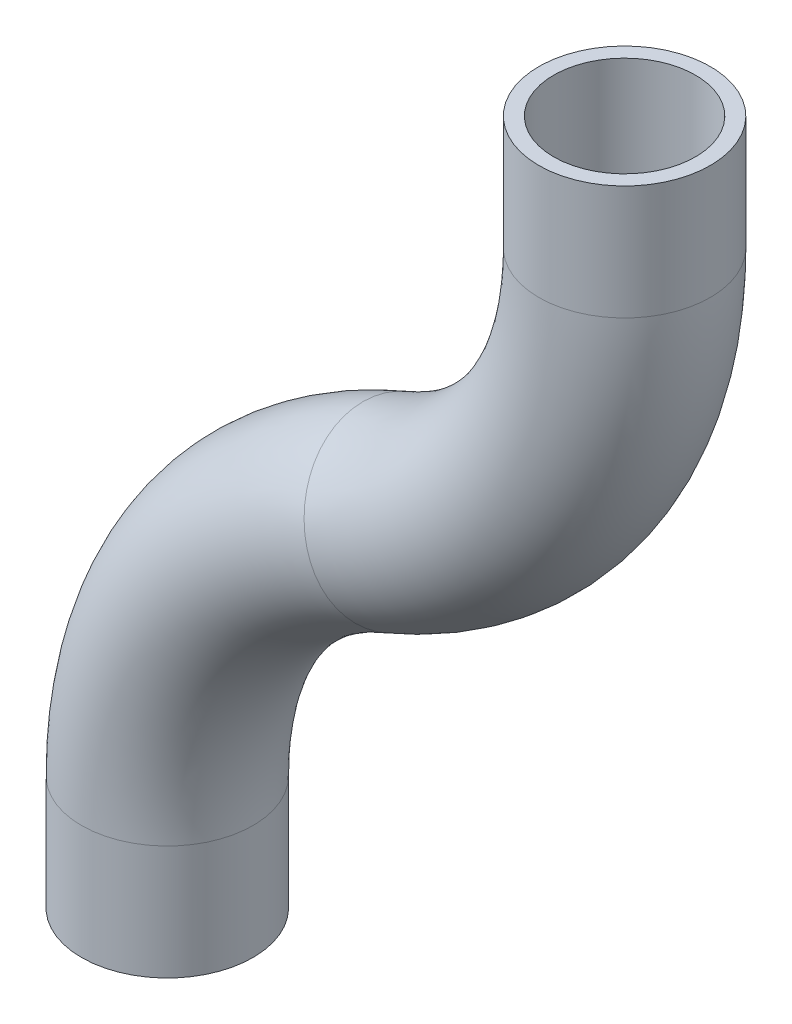
from build123d import *

# Parameters (mm, degrees)
SKETCH1_R   = 9.525
SKETCH1_R_2 = 7.874


with BuildPart() as part:
    # Sweep1: sweep along a path in Sketch2
    with BuildLine(Plane.XY) as sweep1_path:
        Line((0, 0), (0, 12.7))
        ThreePointArc((0, 12.7), (6.932124101, 35.595250599), (25.4, 50.8))
        ThreePointArc((25.4, 50.8), (43.867875899, 66.004749401), (50.8, 88.9))
        Line((50.8, 88.9), (50.8, 101.6))
    # Sketch1 → Sweep1 (sweep)
    with BuildSketch(Plane(origin=(0, 0, 0), x_dir=(1, 0, 0), z_dir=(0, 1, 0))):
        Circle(SKETCH1_R)
        Circle(SKETCH1_R_2, mode=Mode.SUBTRACT)
    sweep(path=sweep1_path.line)


solid = part.part
